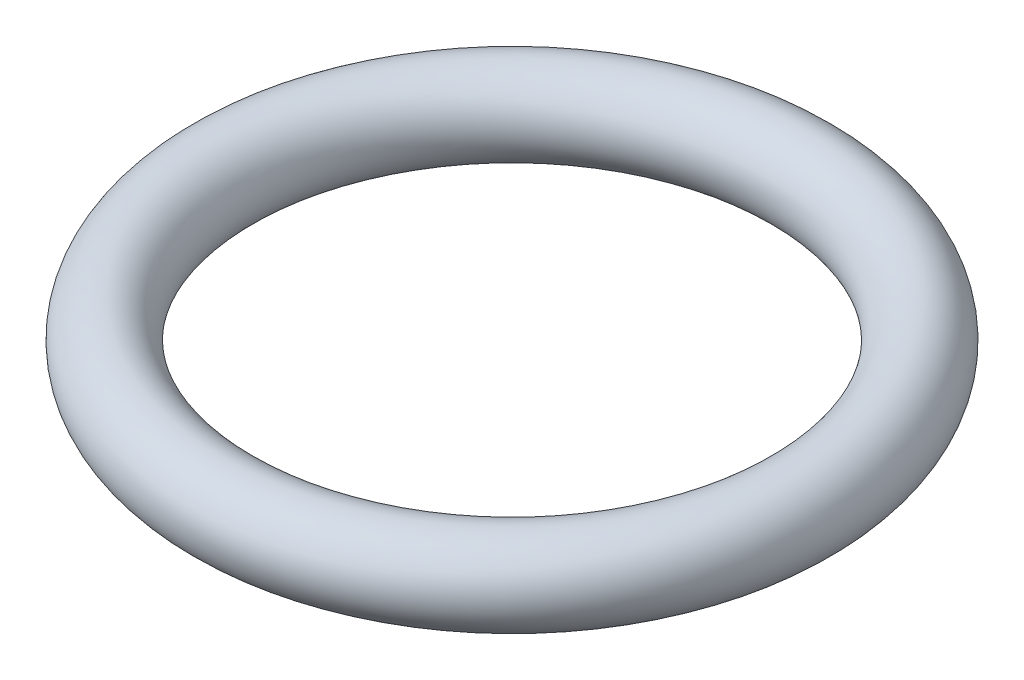
from build123d import *

# Parameters (mm, degrees)
SKETCH1_R = 0.79375


with BuildPart() as part:
    # Sketch1 → Revolve1 (revolve)
    with BuildSketch(Plane.XY, mode=Mode.PRIVATE) as revolve1_sk:
        with Locations((-5.55625, 0)):
            Circle(SKETCH1_R)
    revolve(revolve1_sk.sketch.rotate(Axis((0, 0, 0), (0, 1, 0)), 270), axis=Axis((0, 0, 0), (0, 1, 0)))  # turned: the seam where the file's is


solid = part.part
